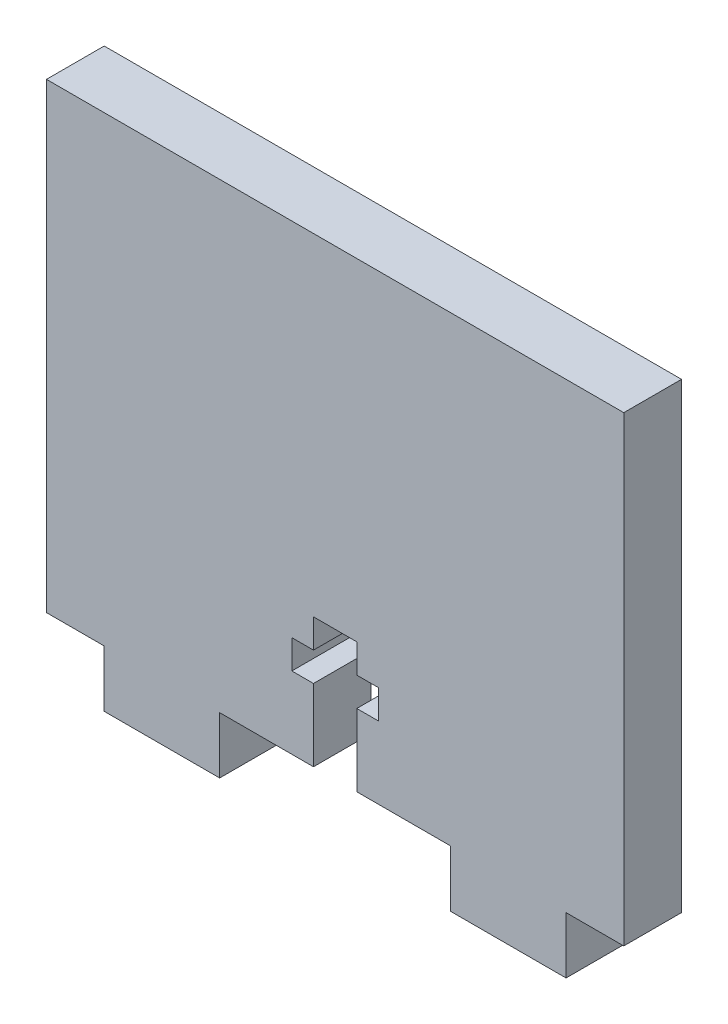
from build123d import *

# Parameters (mm, degrees)
BOSS_EXTRUDE1_DEPTH = 6.35


with BuildPart() as part:
    # Sketch1 → Boss-Extrude1 (new body)
    with BuildSketch(Plane.XY):
        Polygon((29.36875, 11.1125), (26.9875, 11.1125), (26.9875, 7.9375), (29.36875, 7.9375), (29.36875, 0), (19.05, 0), (19.05, -6.227884615), (6.35, -6.227884615), (6.35, 0), (0, 0), (0, 50.8), (63.5, 50.8), (63.5, 0), (57.15, 0), (57.15, -6.227884615), (44.45, -6.227884615), (44.45, 0), (34.13125, 0), (34.13125, 7.9375), (36.5125, 7.9375), (36.5125, 11.1125), (34.13125, 11.1125), (34.13125, 14.2875), (29.36875, 14.2875), align=None)
    extrude(amount=BOSS_EXTRUDE1_DEPTH)


solid = part.part
